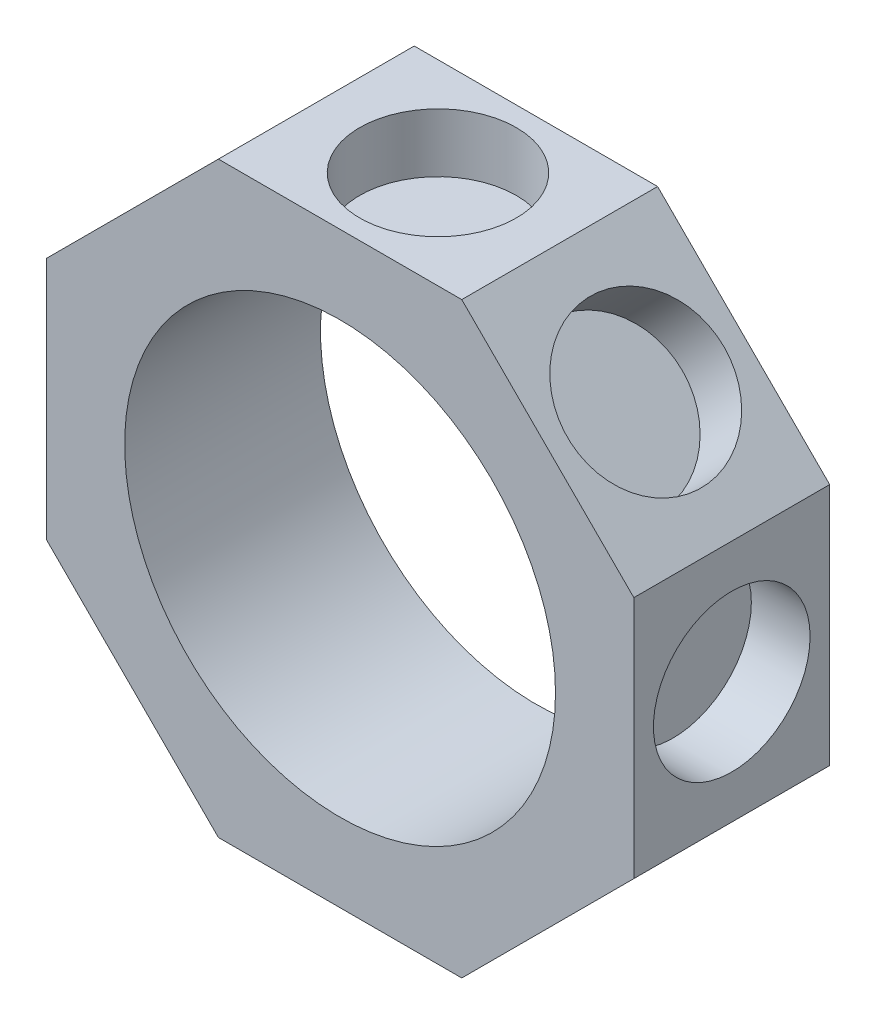
from build123d import *

# Parameters (mm, degrees)
SKETCH1_R           = 11
BOSS_EXTRUDE1_DEPTH = 5
SKETCH2_R           = 4
CUT_EXTRUDE3_DEPTH  = 3
CIRPATTERN1_COUNT   = 8


with BuildPart() as part:
    # Sketch1 → Boss-Extrude1 (new, symmetric)
    with BuildSketch(Plane.XY):
        Polygon((6.213203436, 15), (-6.213203436, 15), (-15, 6.213203436), (-15, -6.213203436), (-6.213203436, -15), (6.213203436, -15), (15, -6.213203436), (15, 6.213203436), align=None)
        Circle(SKETCH1_R, mode=Mode.SUBTRACT)
    extrude(amount=BOSS_EXTRUDE1_DEPTH, both=True)

    # Sketch2 → Cut-Extrude3 (cut)
    with BuildSketch(Plane(origin=(0, -15, 0), x_dir=(-1, 0, 0), z_dir=(0, -1, 0))):
        Circle(SKETCH2_R)
    cut_extrude3 = extrude(amount=-CUT_EXTRUDE3_DEPTH, mode=Mode.SUBTRACT)

    # CirPattern1: Cut-Extrude3 ×8 about axis
    cirpattern1_axis = Axis((0, 0, 5), (0, 0, 1))
    for i in range(1, CIRPATTERN1_COUNT):
        add(cut_extrude3.rotate(cirpattern1_axis, i * 360 / CIRPATTERN1_COUNT), mode=Mode.SUBTRACT)


solid = part.part
